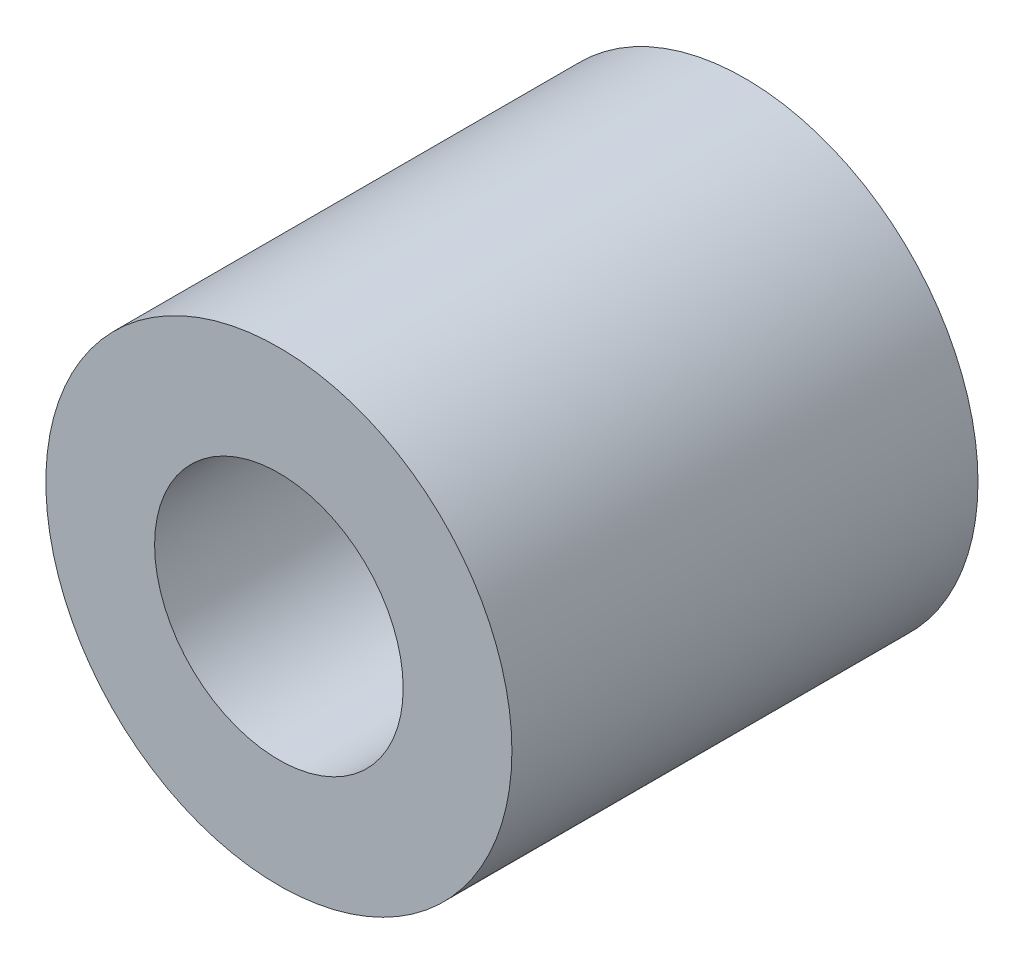
from build123d import *

# Parameters (mm, degrees)
ESQUISSE1_R      = 3
ESQUISSE1_R_2    = 1.6
EXTRUSION1_DEPTH = 6


with BuildPart() as part:
    # Esquisse1 → Extrusion1 (new body)
    with BuildSketch(Plane.XY):
        Circle(ESQUISSE1_R)
        Circle(ESQUISSE1_R_2, mode=Mode.SUBTRACT)
    extrude(amount=EXTRUSION1_DEPTH)


solid = part.part
